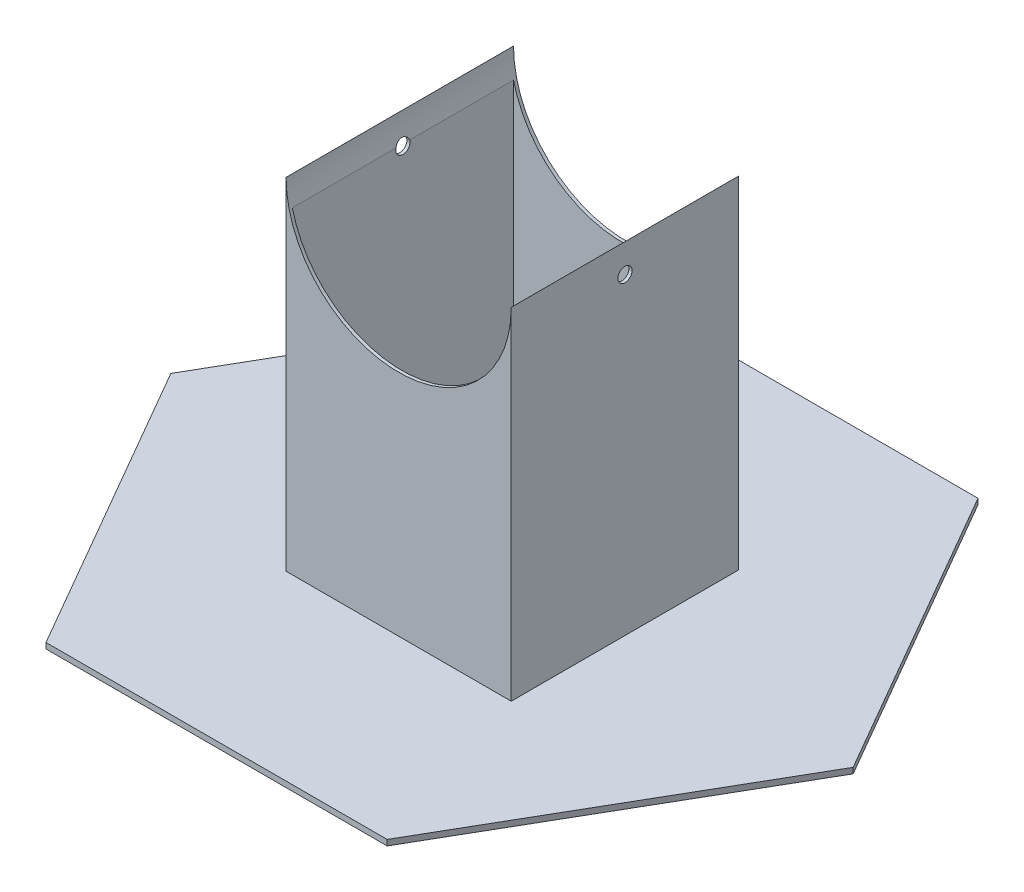
from build123d import *

# Parameters (mm, degrees)
BOSS_EXTRUDE1_DEPTH     = 2.54
SKETCH2_W               = 100.584
SKETCH2_H               = 101.6
BOSS_EXTRUDE2_DEPTH     = 152.4
SKETCH4_W               = 97.79508
SKETCH4_H               = 98.81108
CUT_EXTRUDE1_DEPTH      = 190.5
SKETCH6_R               = 3.175
CUT_EXTRUDE2_DEPTH      = 203.856506729
CUT_EXTRUDE4_DEPTH      = 82.182271537
CUT_EXTRUDE4_DEPTH_BACK = 183.782271537


with BuildPart() as part:
    # Sketch1 → Boss-Extrude1 (new body)
    with BuildSketch(Plane(origin=(0, 0, 0), x_dir=(1, 0, 0), z_dir=(0, 1, 0))):
        Polygon((76.035493271, -131.982271537), (152.235493271, 0), (76.035493271, 131.982271537), (-76.364506729, 131.982271537), (-152.564506729, 0), (-76.364506729, -131.982271537), align=None)
    extrude(amount=BOSS_EXTRUDE1_DEPTH)

    # Sketch2 → Boss-Extrude2 (add)
    with BuildSketch(Plane(origin=(0, 2.54, 0), x_dir=(1, 0, 0), z_dir=(0, 1, 0))):
        Rectangle(SKETCH2_W, SKETCH2_H)
    extrude(amount=BOSS_EXTRUDE2_DEPTH)

    # Sketch4 → Cut-Extrude1 (cut)
    with BuildSketch(Plane(origin=(0, 154.94, 0), x_dir=(1, 0, 0), z_dir=(0, 1, 0))):
        Rectangle(SKETCH4_W, SKETCH4_H)
    extrude(amount=-CUT_EXTRUDE1_DEPTH, mode=Mode.SUBTRACT)

    # Sketch6 → Cut-Extrude2 (cut, through all)
    with BuildSketch(Plane(origin=(50.292, 0, 0), x_dir=(0, 0, -1), z_dir=(1, 0, 0))):
        with Locations((0, 142.24)):
            Circle(SKETCH6_R)
    extrude(amount=-CUT_EXTRUDE2_DEPTH, mode=Mode.SUBTRACT)

    # Sketch7 → Cut-Extrude4 (cut, two sides)
    with BuildSketch(Plane(origin=(0, 0, -50.8), x_dir=(-1, 0, 0), z_dir=(0, 0, -1))) as cut_extrude4_sk:
        with BuildLine():
            Line((-50.292, 675.458034637), (-50.292, 154.94))
            ThreePointArc((-50.292, 154.94), (0, 104.648), (50.292, 154.94))
            Line((50.292, 154.94), (50.292, 675.458034637))
            Line((50.292, 675.458034637), (50.292, 1716.494103911))
            Line((50.292, 1716.494103911), (-50.292, 1716.494103911))
            Line((-50.292, 1716.494103911), (-50.292, 675.458034637))
        make_face()
    extrude(amount=CUT_EXTRUDE4_DEPTH, mode=Mode.SUBTRACT)
    extrude(cut_extrude4_sk.sketch, amount=-CUT_EXTRUDE4_DEPTH_BACK, mode=Mode.SUBTRACT)


solid = part.part
